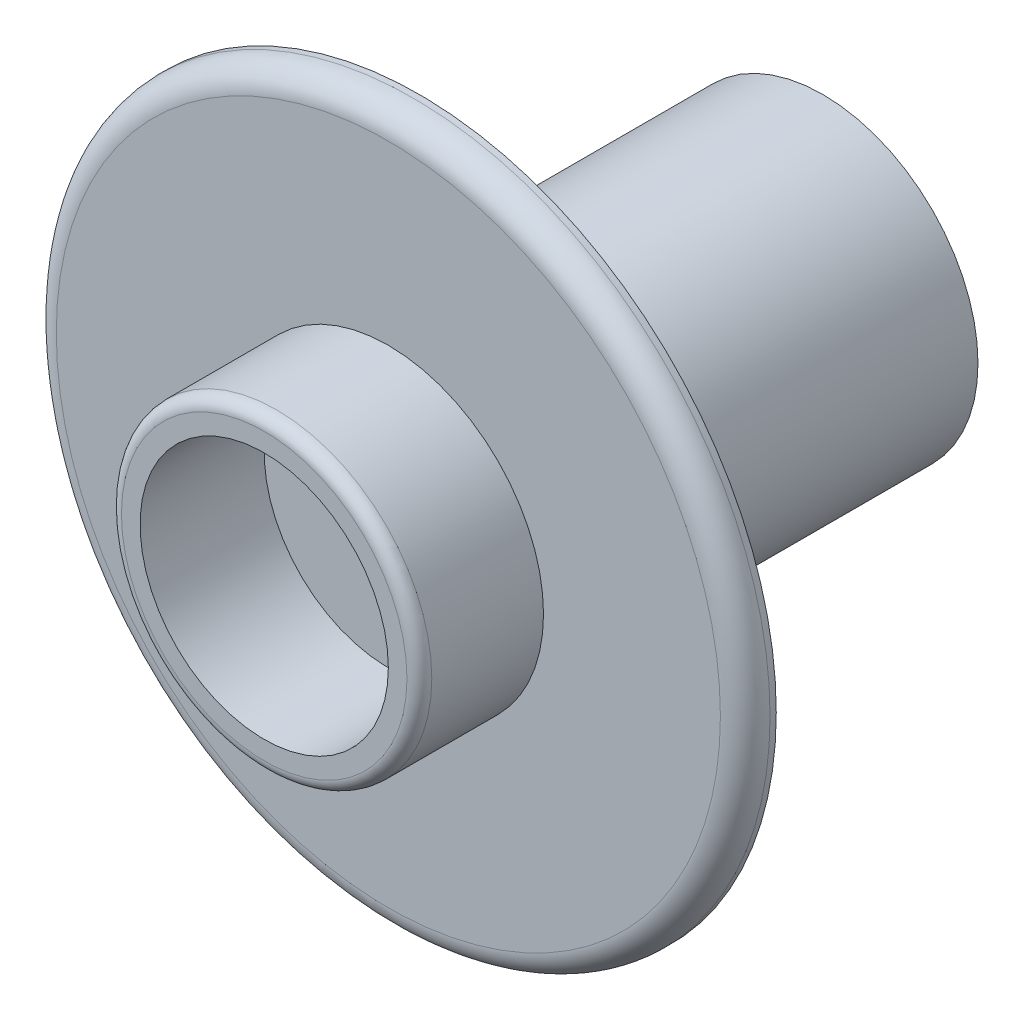
from build123d import *

# Parameters (mm, degrees)
SKETCH1_R           = 36.5125
BOSS_EXTRUDE1_DEPTH = 3.175
SKETCH2_R           = 15.875
BOSS_EXTRUDE2_DEPTH = 41.275
BOSS_EXTRUDE3_START = -15.875
SKETCH2_2_R         = 15.875
BOSS_EXTRUDE3_DEPTH = 15.875
SKETCH3_R           = 12.7
CUT_EXTRUDE1_DEPTH  = 12.7
FILLET1_R           = 2.54
FILLET2_R           = 1.27


with BuildPart() as part:
    # Sketch1 → Boss-Extrude1 (new body)
    with BuildSketch(Plane.XY):
        Circle(SKETCH1_R)
    extrude(amount=BOSS_EXTRUDE1_DEPTH)

    # Sketch2 → Boss-Extrude2 (add)
    with BuildSketch(Plane(origin=(0, 0, 0), x_dir=(-1, 0, 0), z_dir=(0, 0, -1))):
        Circle(SKETCH2_R)
    extrude(amount=BOSS_EXTRUDE2_DEPTH)

    # Sketch2_2 → Boss-Extrude3 (add)
    with BuildSketch(Plane(origin=(0, 0, 0), x_dir=(-1, 0, 0), z_dir=(0, 0, -1)).offset(BOSS_EXTRUDE3_START)):
        Circle(SKETCH2_2_R)
    extrude(amount=BOSS_EXTRUDE3_DEPTH)

    # Sketch3 → Cut-Extrude1 (cut)
    with BuildSketch(Plane.XY.offset(15.875)):
        Circle(SKETCH3_R)
    extrude(amount=-CUT_EXTRUDE1_DEPTH, mode=Mode.SUBTRACT)

    # Fillet1
    fillet1_edges = [part.edges().sort_by_distance(p)[0] for p in [
        (-36.5125, 0, 3.175),
    ]]
    fillet(fillet1_edges, radius=FILLET1_R)

    # Fillet2
    fillet2_edges = [part.edges().sort_by_distance(p)[0] for p in [
        (15.875, 0, 15.875),
    ]]
    fillet(fillet2_edges, radius=FILLET2_R)


solid = part.part
